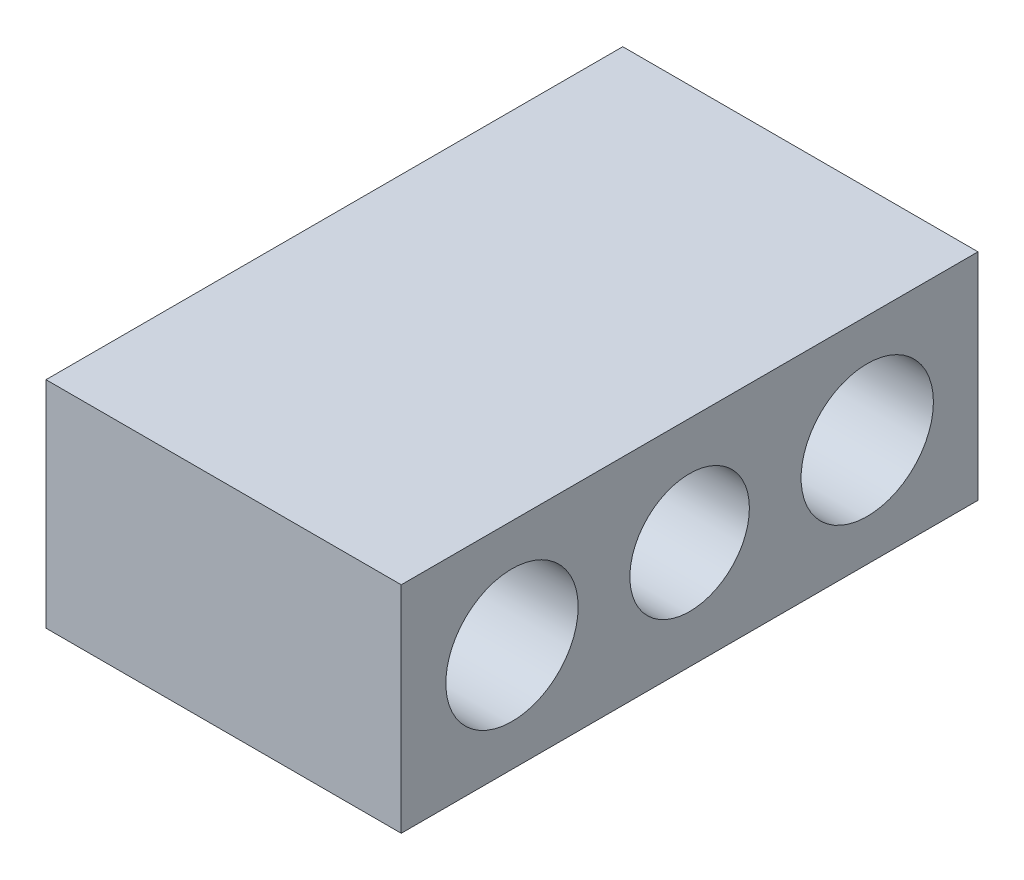
from build123d import *

# Parameters (mm, degrees)
SKETCH1_W           = 85
SKETCH1_H           = 138
BOSS_EXTRUDE1_DEPTH = 51.5
CUT_EXTRUDE2_REACH  = 87
SKETCH3_R           = 14.3
SKETCH3_R_2         = 15.83


with BuildPart() as part:
    # Sketch1 → Boss-Extrude1 (new body)
    with BuildSketch(Plane(origin=(0, 0, 0), x_dir=(1, 0, 0), z_dir=(0, 1, 0))):
        with Locations((42.5, 69)):
            Rectangle(SKETCH1_W, SKETCH1_H)
    extrude(amount=BOSS_EXTRUDE1_DEPTH)

    # Sketch3 → Cut-Extrude2 (cut, up to next)
    with BuildSketch(Plane(origin=(85, 0, 0), x_dir=(0, 0, -1), z_dir=(1, 0, 0)), mode=Mode.PRIVATE) as cut_extrude2_sk1:
        with Locations((69, 25.75)):
            Circle(SKETCH3_R)
    cut_extrude2_tool1 = extrude(cut_extrude2_sk1.sketch, amount=-CUT_EXTRUDE2_REACH, mode=Mode.PRIVATE) & part.part
    add(cut_extrude2_tool1.solids().sort_by_distance((85, 25.75, -69))[0], mode=Mode.SUBTRACT)
    # Sketch3 → Cut-Extrude2 (cut, up to next)
    with BuildSketch(Plane(origin=(85, 0, 0), x_dir=(0, 0, -1), z_dir=(1, 0, 0)), mode=Mode.PRIVATE) as cut_extrude2_sk2:
        with Locations((26.5, 25.75)):
            Circle(SKETCH3_R_2)
    cut_extrude2_tool2 = extrude(cut_extrude2_sk2.sketch, amount=-CUT_EXTRUDE2_REACH, mode=Mode.PRIVATE) & part.part
    add(cut_extrude2_tool2.solids().sort_by_distance((85, 25.75, -26.5))[0], mode=Mode.SUBTRACT)
    # Sketch3 → Cut-Extrude2 (cut, up to next)
    with BuildSketch(Plane(origin=(85, 0, 0), x_dir=(0, 0, -1), z_dir=(1, 0, 0)), mode=Mode.PRIVATE) as cut_extrude2_sk3:
        with Locations((111.5, 25.75)):
            Circle(SKETCH3_R_2)
    cut_extrude2_tool3 = extrude(cut_extrude2_sk3.sketch, amount=-CUT_EXTRUDE2_REACH, mode=Mode.PRIVATE) & part.part
    add(cut_extrude2_tool3.solids().sort_by_distance((85, 25.75, -111.5))[0], mode=Mode.SUBTRACT)


solid = part.part
